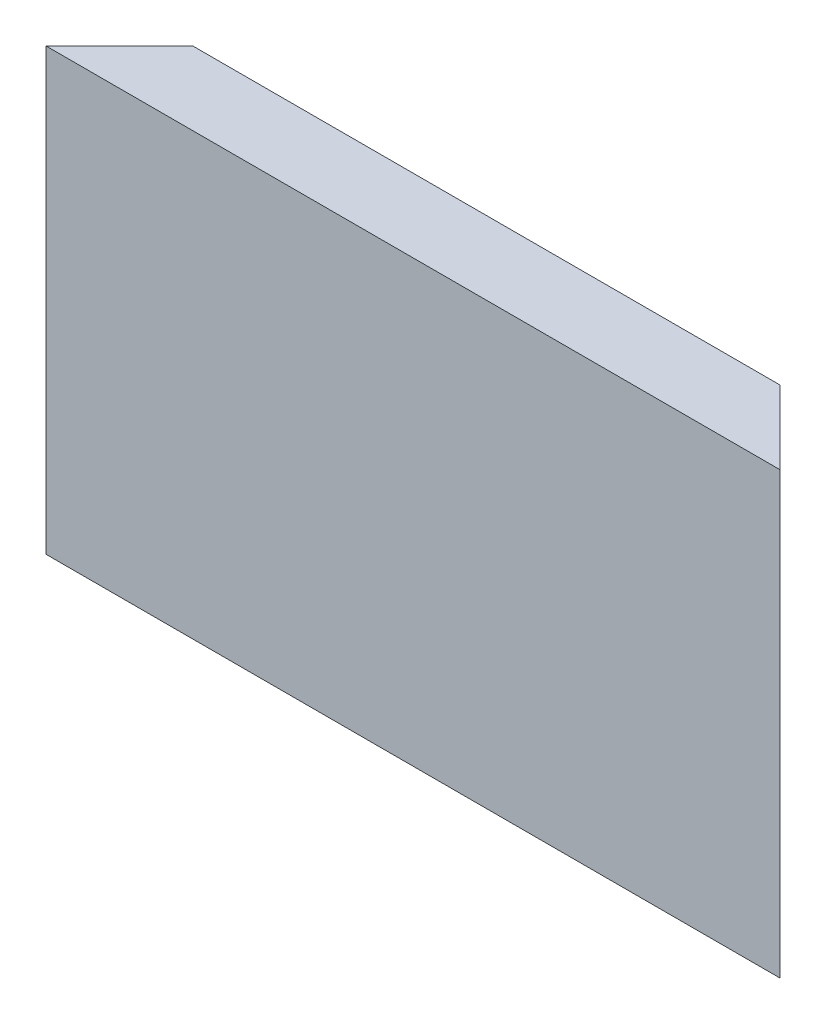
from build123d import *

# Parameters (mm, degrees)
SKETCH1_W               = 50
SKETCH1_H               = 30
BOSS_EXTRUDE1_DEPTH     = 5
CUT_EXTRUDE3_DEPTH      = 1
CUT_EXTRUDE3_DEPTH_BACK = 31
CUT_EXTRUDE4_DEPTH      = 26
CUT_EXTRUDE4_DEPTH_BACK = 26


with BuildPart() as part:
    # Sketch1 → Boss-Extrude1 (new body)
    with BuildSketch(Plane.XY):
        Rectangle(SKETCH1_W, SKETCH1_H)
    extrude(amount=BOSS_EXTRUDE1_DEPTH)

    # Sketch4 → Cut-Extrude3 (cut, two sides)
    with BuildSketch(Plane(origin=(0, 15, 0), x_dir=(1, 0, 0), z_dir=(0, 1, 0))) as cut_extrude3_sk:
        Polygon((-25, -5), (-20, 0), (-25, 0), align=None)
        Polygon((25, -5), (20, 0), (25, 0), align=None)
    extrude(amount=CUT_EXTRUDE3_DEPTH, mode=Mode.SUBTRACT)
    extrude(cut_extrude3_sk.sketch, amount=-CUT_EXTRUDE3_DEPTH_BACK, mode=Mode.SUBTRACT)

    # Sketch5 → Cut-Extrude4 (cut, two sides)
    with BuildSketch(Plane(origin=(0, 0, 0), x_dir=(0, 0, -1), z_dir=(1, 0, 0))) as cut_extrude4_sk:
        Polygon((-5, -15), (0, -10), (0, -15), align=None)
    extrude(amount=CUT_EXTRUDE4_DEPTH, mode=Mode.SUBTRACT)
    extrude(cut_extrude4_sk.sketch, amount=-CUT_EXTRUDE4_DEPTH_BACK, mode=Mode.SUBTRACT)


solid = part.part
